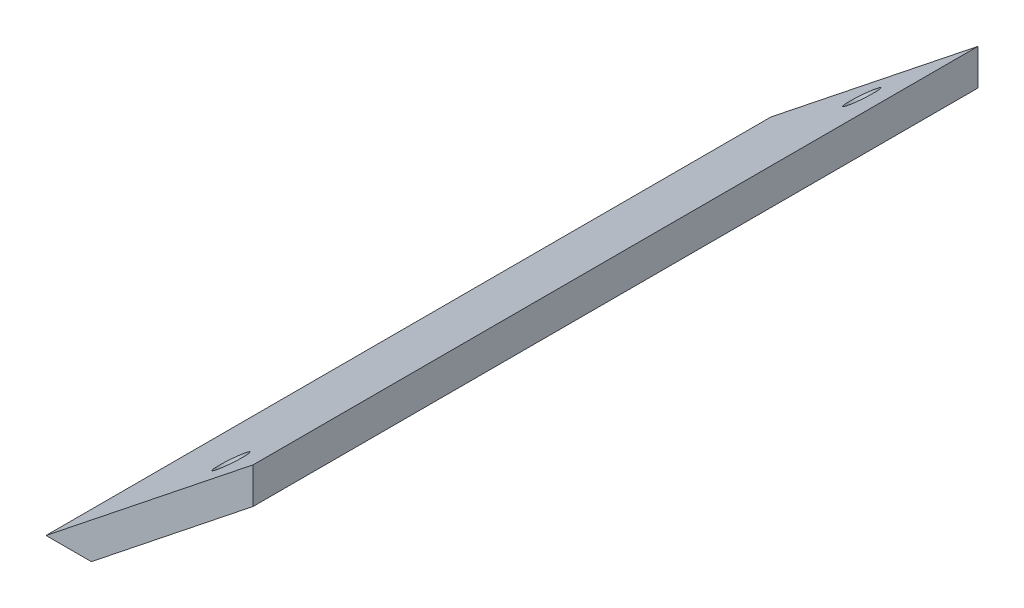
from build123d import *

# Parameters (mm, degrees)
SALIENTE_EXTRUIR1_DEPTH = 77
CORTAR_EXTRUIR1_REACH   = 15.696
CROQUIS2_R              = 1.6


with BuildPart() as part:
    # Croquis1 → Saliente-Extruir1 (new body)
    with BuildSketch(Plane.XY):
        Polygon((-22, 0), (-17.180905327, 0), (0, 13.666629237), (0, 17.5), align=None)
    extrude(amount=SALIENTE_EXTRUIR1_DEPTH)

    # Croquis2 → Cortar-Extruir1 (cut, up to next)
    with BuildSketch(Plane(origin=(-8.52578298, 10.718127175, 0), x_dir=(0.782601054, 0.622523566, 0), z_dir=(-0.622523566, 0.782601054, 0)), mode=Mode.PRIVATE) as cortar_extruir1_sk1:
        with Locations((1.507798766, -5)):
            Circle(CROQUIS2_R)
    cortar_extruir1_tool1 = extrude(cortar_extruir1_sk1.sketch, amount=-CORTAR_EXTRUIR1_REACH, mode=Mode.PRIVATE) & part.part
    add(cortar_extruir1_tool1.solids().sort_by_distance((-7.345778, 11.656767, 5))[0], mode=Mode.SUBTRACT)
    # Croquis2 → Cortar-Extruir1 (cut, up to next)
    with BuildSketch(Plane(origin=(-8.52578298, 10.718127175, 0), x_dir=(0.782601054, 0.622523566, 0), z_dir=(-0.622523566, 0.782601054, 0)), mode=Mode.PRIVATE) as cortar_extruir1_sk2:
        with Locations((1.507798766, -72)):
            Circle(CROQUIS2_R)
    cortar_extruir1_tool2 = extrude(cortar_extruir1_sk2.sketch, amount=-CORTAR_EXTRUIR1_REACH, mode=Mode.PRIVATE) & part.part
    add(cortar_extruir1_tool2.solids().sort_by_distance((-7.345778, 11.656767, 72))[0], mode=Mode.SUBTRACT)


solid = part.part
